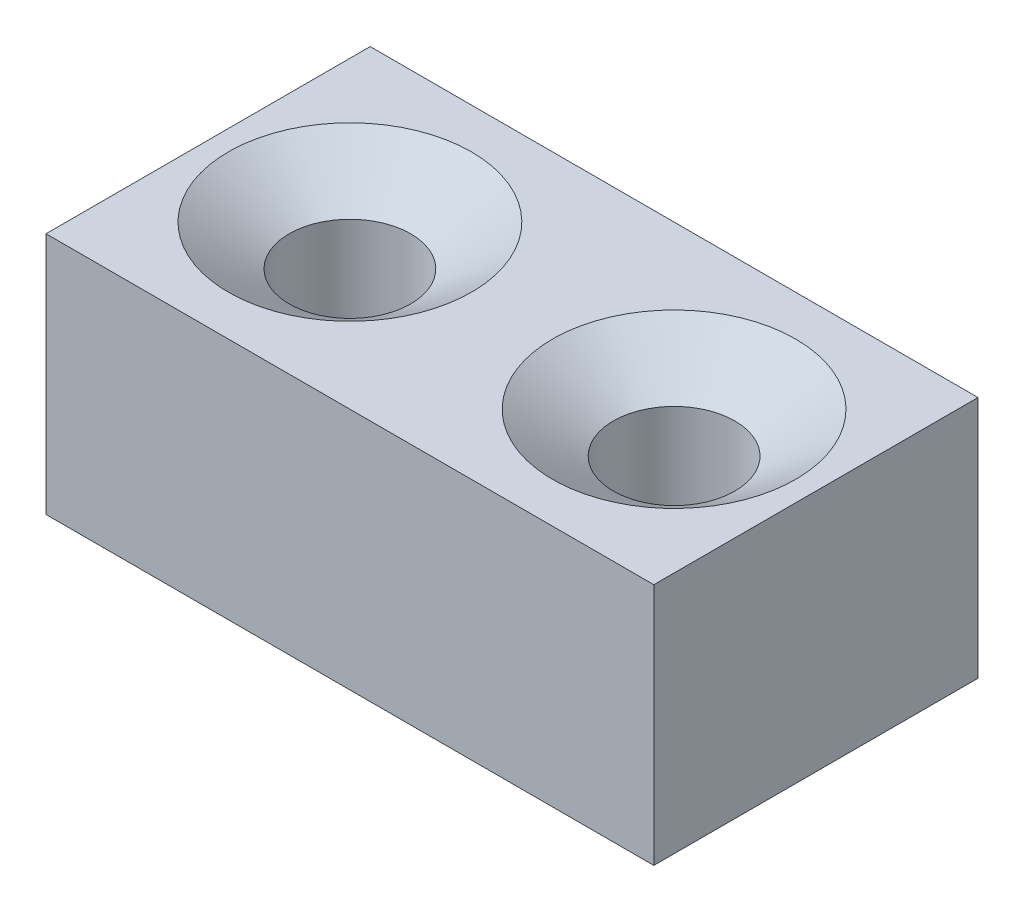
from build123d import *

# Parameters (mm, degrees)
SKETCH1_W           = 150
SKETCH1_H           = 80
BOSS_EXTRUDE1_DEPTH = 60


with BuildPart() as part:
    # Sketch1 → Boss-Extrude1 (new body)
    with BuildSketch(Plane(origin=(0, 0, 0), x_dir=(1, 0, 0), z_dir=(0, 1, 0))):
        Rectangle(SKETCH1_W, SKETCH1_H)
    extrude(amount=BOSS_EXTRUDE1_DEPTH)

    # Sketch2 → Cut-Revolve1 (revolve, cut)
    with BuildSketch(Plane.XY):
        Polygon((-40, 60), (-70, 60), (-55, 50), (-55, 10), (-40, 10), align=None)
    cut_revolve1 = revolve(axis=Axis((-40, 10, 0), (0, 1, 0)), mode=Mode.SUBTRACT)

    # Mirror1: Cut-Revolve1 across plane
    add(cut_revolve1.mirror(Plane(origin=(0, 0, 0), x_dir=(0, 0, 1), z_dir=(1, 0, 0))), mode=Mode.SUBTRACT)


solid = part.part
